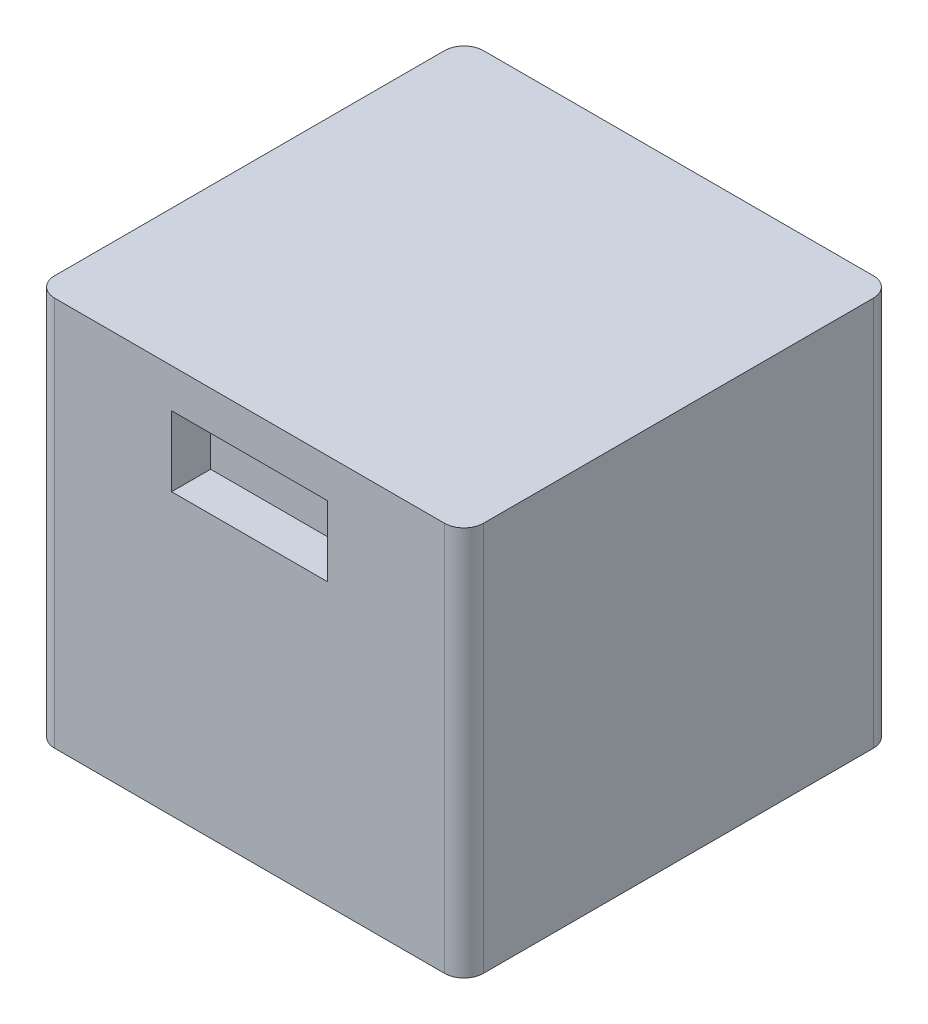
from build123d import *

# Parameters (mm, degrees)
SKETCH1_W           = 220
SKETCH1_H           = 220
BOSS_EXTRUDE1_DEPTH = 200
FILLET1_R           = 10
SKETCH2_R           = 30
CUT_EXTRUDE1_DEPTH  = 20
SKETCH3_W           = 80
SKETCH3_H           = 36
CUT_EXTRUDE2_DEPTH  = 20
SKETCH4_W           = 13.191247326
SKETCH4_H           = 23.565374265
CUT_EXTRUDE3_DEPTH  = 10


with BuildPart() as part:
    # Sketch1 → Boss-Extrude1 (new body)
    with BuildSketch(Plane(origin=(0, 0, 0), x_dir=(1, 0, 0), z_dir=(0, 1, 0))):
        Rectangle(SKETCH1_W, SKETCH1_H)
    extrude(amount=BOSS_EXTRUDE1_DEPTH)

    # Fillet1
    fillet1_edges = [part.edges().sort_by_distance(p)[0] for p in [
        (110, 100, 110),
        (-110, 100, 110),
        (-110, 100, -110),
        (110, 100, -110),
    ]]
    fillet(fillet1_edges, radius=FILLET1_R)

    # Sketch2 → Cut-Extrude1 (cut)
    with BuildSketch(Plane.XZ):
        with Locations((0, -50)):
            Circle(SKETCH2_R)
        with Locations((0, 60)):
            Circle(SKETCH2_R)
    extrude(amount=-CUT_EXTRUDE1_DEPTH, mode=Mode.SUBTRACT)

    # Sketch3 → Cut-Extrude2 (cut)
    with BuildSketch(Plane.XY.offset(110)):
        with Locations((0, 162)):
            Rectangle(SKETCH3_W, SKETCH3_H)
    extrude(amount=-CUT_EXTRUDE2_DEPTH, mode=Mode.SUBTRACT)

    # Sketch4 → Cut-Extrude3 (cut)
    with BuildSketch(Plane.ZY.offset(-40)):
        with Locations((100, 164.204493947)):
            Rectangle(SKETCH4_W, SKETCH4_H)
    extrude(amount=-CUT_EXTRUDE3_DEPTH, mode=Mode.SUBTRACT)


solid = part.part
